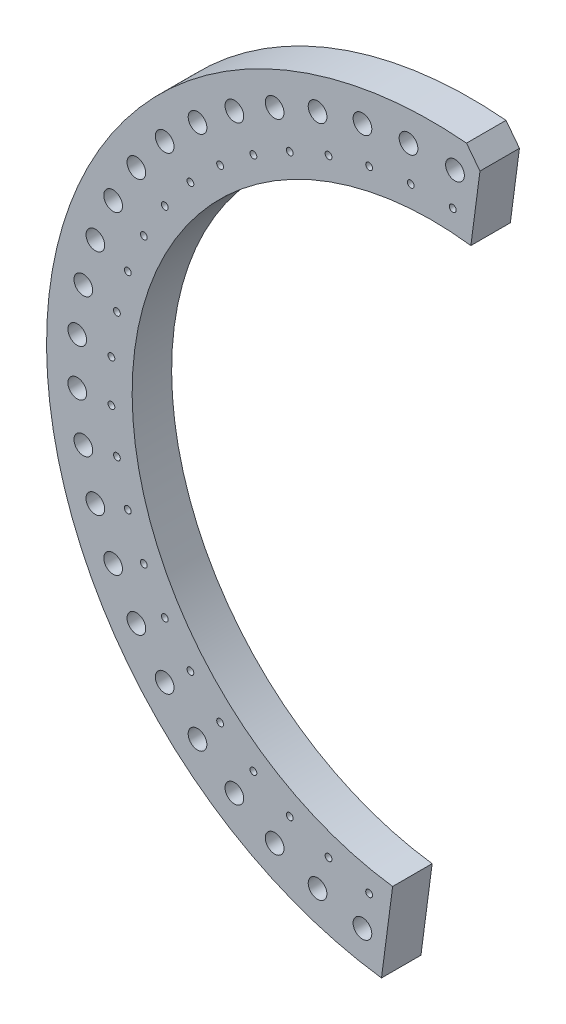
from build123d import *

# Parameters (mm, degrees)
EXTRUDE5_DEPTH     = 2.30625
SKETCH31_R         = 0.396875
SKETCH31_R_2       = 1.0922
CUT_EXTRUDE4_DEPTH = 5.6125
CIRPATTERN1_COUNT  = 24
CIRPATTERN1_ANGLE  = 172.5
CUT_EXTRUDE5_DEPTH = 5.6125


with BuildPart() as part:
    # Sketch7 → Extrude5 (new body, symmetric)
    with BuildSketch(Plane.XY):
        with BuildLine():
            Line((5.87367865, 44.615018762), (4.568416728, 34.700570148))
            ThreePointArc((4.568416728, 34.700570148), (-34.700570148, 4.568416728), (-4.568416728, -34.700570148))
            Line((-4.568416728, -34.700570148), (-5.87367865, -44.615018762))
            ThreePointArc((-5.87367865, -44.615018762), (-44.615018762, 5.87367865), (5.87367865, 44.615018762))
        make_face()
    extrude(amount=EXTRUDE5_DEPTH, both=True)

    # Sketch31 → Cut-Extrude4 (cut, through all)
    with BuildSketch(Plane.XY.offset(2.30625)):
        with Locations((-7.315887076, -36.779448015)):
            Circle(SKETCH31_R)
        with Locations((-8.096248364, -40.702589137)):
            Circle(SKETCH31_R_2)
    cut_extrude4 = extrude(amount=-CUT_EXTRUDE4_DEPTH, mode=Mode.SUBTRACT)

    # CirPattern1: Cut-Extrude4 ×24 about axis
    cirpattern1_axis = Axis((0, 0, 0), (0, 0, -1))
    for i in range(1, CIRPATTERN1_COUNT):
        add(cut_extrude4.rotate(cirpattern1_axis, i * CIRPATTERN1_ANGLE / (CIRPATTERN1_COUNT - 1)), mode=Mode.SUBTRACT)

    # Sketch32 → Cut-Extrude5 (cut, through all)
    with BuildSketch(Plane.XY.offset(2.30625)):
        with BuildLine():
            Line((4.061625331, 44.816327378), (5.630931125, 42.77116825))
            Line((5.630931125, 42.77116825), (5.87367865, 44.615018762))
            ThreePointArc((5.87367865, 44.615018762), (4.968671612, 44.724851061), (4.061625331, 44.816327378))
        make_face()
    extrude(amount=-CUT_EXTRUDE5_DEPTH, mode=Mode.SUBTRACT)


solid = part.part
